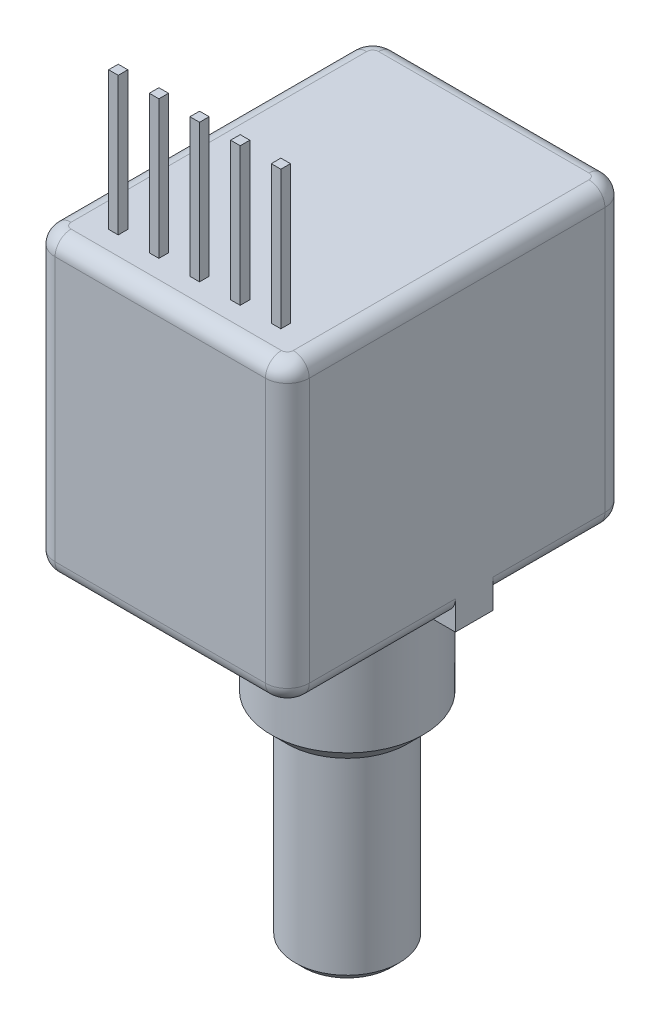
from build123d import *

# Parameters (mm, degrees)
SKETCH_2_W      = 15.88
SKETCH_2_H      = 21.21
EXTRUDE_1_DEPTH = 18.5
FILLET_1_R      = 1.37
FILLET_2_R      = 1
SKETCH_3_R      = 4.7625
EXTRUDE_2_DEPTH = 9.53
SKETCH_4_R      = 3.25
EXTRUDE_3_DEPTH = 12.6
CHAMFER_1_SIZE  = 0.5
CHAMFER_2_SIZE  = 1
SKETCH_5_R      = 5.2
EXTRUDE_4_DEPTH = 1.57
SKETCH_6_W      = 1.37
SKETCH_6_H      = 2.36
EXTRUDE_5_DEPTH = 0.8
SKETCH_6_3_W    = 1.37
SKETCH_6_3_H    = 2.36
EXTRUDE_6_DEPTH = 2
SKETCH_7_W      = 0.6
SKETCH_7_H      = 0.6
EXTRUDE_7_DEPTH = 8.636


with BuildPart() as part:
    # Эскиз2 → Бобышка-Вытянуть1 (new body)
    with BuildSketch(Plane(origin=(0, 0, 0), x_dir=(1, 0, 0), z_dir=(0, 1, 0))):
        with Locations((7.94, 10.605)):
            Rectangle(SKETCH_2_W, SKETCH_2_H)
    extrude(amount=EXTRUDE_1_DEPTH)

    # Скругление1
    fillet_1_edges = [part.edges().sort_by_distance(p)[0] for p in [
        (0, 9.25, -21.21),
        (15.88, 9.25, -21.21),
        (15.88, 9.25, 0),
        (0, 9.25, 0),
    ]]
    fillet(fillet_1_edges, radius=FILLET_1_R)

    # Скругление2
    fillet_2_edges = [part.edges().sort_by_distance(p)[0] for p in [
        (15.47873629, 18.5, -20.80873629),
        (15.88, 18.5, -10.605),
        (15.47873629, 18.5, -0.40126371),
        (7.94, 18.5, 0),
        (0.40126371, 18.5, -0.40126371),
        (0, 18.5, -10.605),
        (0.40126371, 18.5, -20.80873629),
        (15.47873629, 0, -20.80873629),
        (15.88, 0, -10.605),
        (15.47873629, 0, -0.40126371),
        (7.94, 0, 0),
        (0.40126371, 0, -0.40126371),
        (0, 0, -10.605),
        (0.40126371, 0, -20.80873629),
        (7.94, 18.5, -21.21),
        (7.94, 0, -21.21),
    ]]
    fillet(fillet_2_edges, radius=FILLET_2_R)

    # Эскиз3 → Бобышка-Вытянуть2 (add)
    with BuildSketch(Plane.XZ):
        with Locations((7.94, -11.68)):
            Circle(SKETCH_3_R)
    extrude(amount=EXTRUDE_2_DEPTH)

    # Эскиз4 → Бобышка-Вытянуть3 (add)
    with BuildSketch(Plane.XZ.offset(9.53)):
        with Locations((7.94, -11.68)):
            Circle(SKETCH_4_R)
    extrude(amount=EXTRUDE_3_DEPTH)

    # Фаска1
    chamfer_1_edges = [part.edges().sort_by_distance(p)[0] for p in [
        (4.69, -22.13, -11.68),
    ]]
    chamfer(chamfer_1_edges, length=CHAMFER_1_SIZE)

    # Фаска2
    chamfer_2_edges = [part.edges().sort_by_distance(p)[0] for p in [
        (3.1775, -9.53, -11.68),
    ]]
    chamfer(chamfer_2_edges, length=CHAMFER_2_SIZE)

    # Эскиз5 → Бобышка-Вытянуть4 (add)
    with BuildSketch(Plane.XZ):
        with Locations((7.94, -11.68)):
            Circle(SKETCH_5_R)
    extrude(amount=EXTRUDE_4_DEPTH)

    # Эскиз6 → Бобышка-Вытянуть5 (add)
    with BuildSketch(Plane.XZ):
        with Locations((15.195, -11.68)):
            Rectangle(SKETCH_6_W, SKETCH_6_H)
    extrude(amount=EXTRUDE_5_DEPTH)

    # Эскиз6<3> → Бобышка-Вытянуть6 (add)
    with BuildSketch(Plane.XZ):
        with Locations((15.195, -11.68)):
            Rectangle(SKETCH_6_3_W, SKETCH_6_3_H)
    extrude(amount=-EXTRUDE_6_DEPTH)

    # Эскиз7 → Бобышка-Вытянуть7 (add)
    with BuildSketch(Plane(origin=(0, 18.5, 0), x_dir=(1, 0, 0), z_dir=(0, 1, 0))):
        with Locations((7.94, 2.455)):
            Rectangle(SKETCH_7_W, SKETCH_7_H)
        with Locations((10.48, 2.455)):
            Rectangle(SKETCH_7_W, SKETCH_7_H)
        with Locations((13.02, 2.455)):
            Rectangle(SKETCH_7_W, SKETCH_7_H)
        with Locations((5.4, 2.455)):
            Rectangle(SKETCH_7_W, SKETCH_7_H)
        with Locations((2.86, 2.455)):
            Rectangle(SKETCH_7_W, SKETCH_7_H)
    extrude(amount=EXTRUDE_7_DEPTH)


solid = part.part
